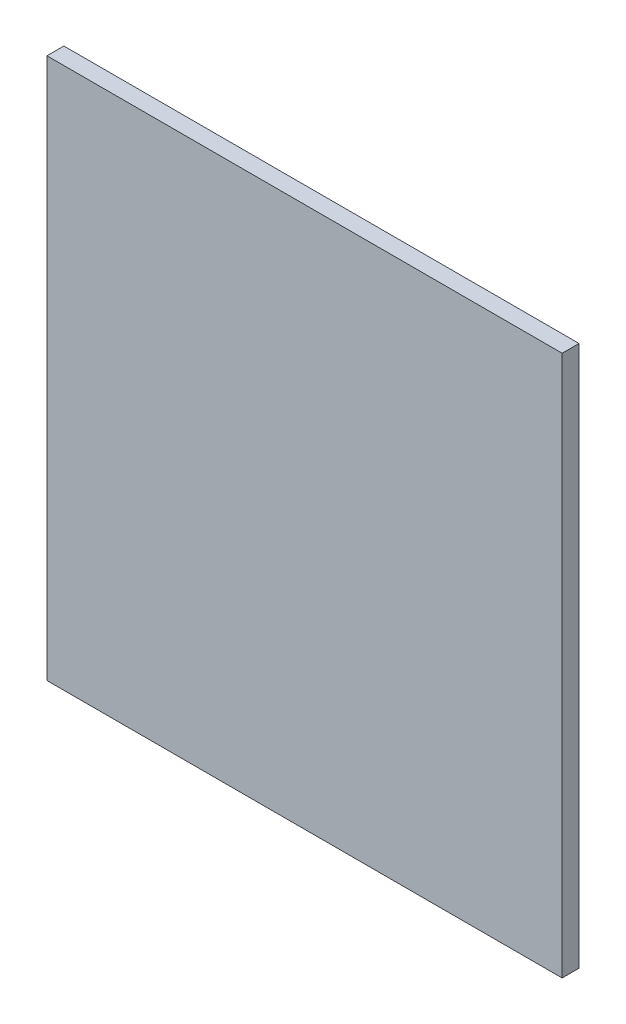
from build123d import *

# Parameters (mm, degrees)
SKETCH1_W           = 193.49
SKETCH1_H           = 203.2
BOSS_EXTRUDE1_DEPTH = 6.35


with BuildPart() as part:
    # Sketch1 → Boss-Extrude1 (new body)
    with BuildSketch(Plane.XY):
        with Locations((96.745, 101.6)):
            Rectangle(SKETCH1_W, SKETCH1_H)
    extrude(amount=BOSS_EXTRUDE1_DEPTH)


solid = part.part
